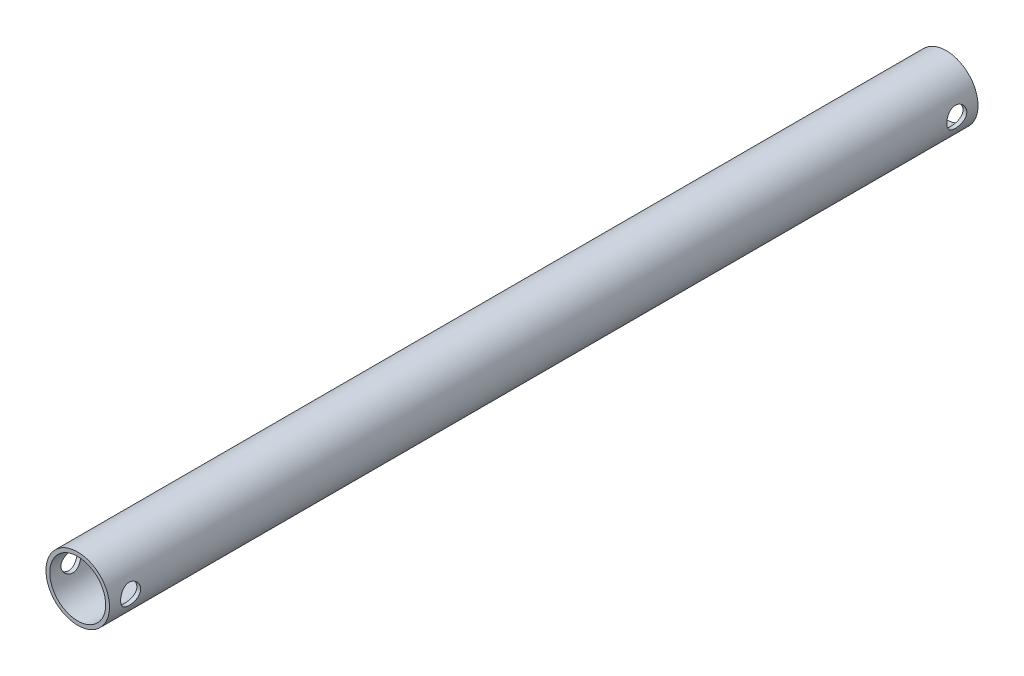
from build123d import *

# Parameters (mm, degrees)
SKETCH1_R           = 9.525
SKETCH1_R_2         = 8.382
BOSS_EXTRUDE1_DEPTH = 260.35
SKETCH2_R           = 3
CUT_EXTRUDE1_DEPTH  = 20.05


with BuildPart() as part:
    # Sketch1 → Boss-Extrude1 (new body)
    with BuildSketch(Plane.XY):
        Circle(SKETCH1_R)
        Circle(SKETCH1_R_2, mode=Mode.SUBTRACT)
    extrude(amount=BOSS_EXTRUDE1_DEPTH)

    # Sketch2 → Cut-Extrude1 (cut, through all)
    with BuildSketch(Plane(origin=(9.525, 0, 0), x_dir=(0, 0, -1), z_dir=(1, 0, 0))):
        with Locations((-254, 0)):
            Circle(SKETCH2_R)
        with Locations((-6.35, 0)):
            Circle(SKETCH2_R)
    extrude(amount=-CUT_EXTRUDE1_DEPTH, mode=Mode.SUBTRACT)


solid = part.part
